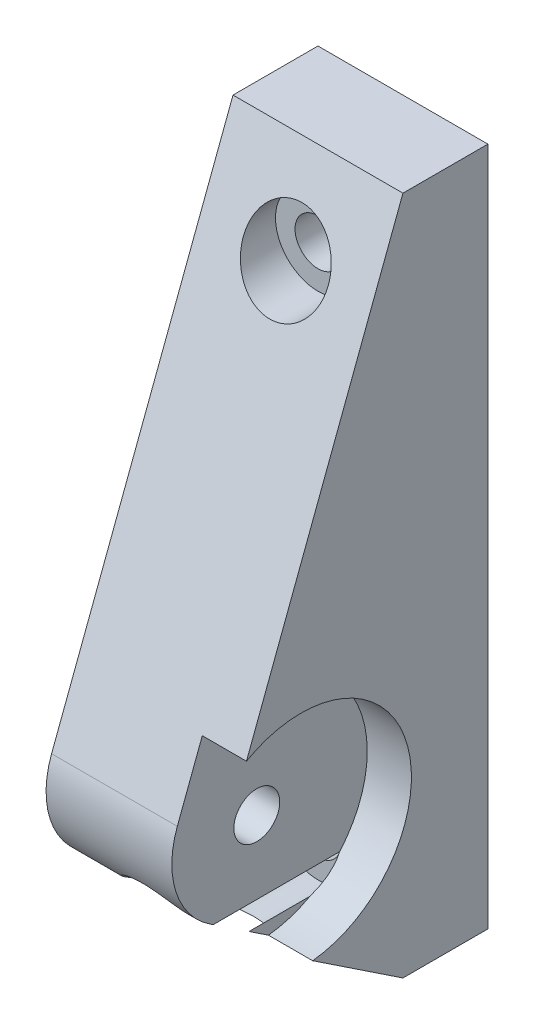
from build123d import *

# Parameters (mm, degrees)
SKETCH1_W           = 20
SKETCH1_H           = 80
SKETCH1_R           = 2.7
BOSS_EXTRUDE1_DEPTH = 10
SKETCH2_R           = 2.7
BOSS_EXTRUDE2_DEPTH = 10
SKETCH3_R           = 5
CUT_EXTRUDE1_DEPTH  = 75.054034326
SKETCH4_R           = 13
CUT_EXTRUDE2_DEPTH  = 5.2


with BuildPart() as part:
    # Sketch1 → Boss-Extrude1 (new body)
    with BuildSketch(Plane.XY):
        with Locations((0, -30)):
            Rectangle(SKETCH1_W, SKETCH1_H)
        Circle(SKETCH1_R, mode=Mode.SUBTRACT)
        with Locations((0, -60)):
            Circle(SKETCH1_R, mode=Mode.SUBTRACT)
    extrude(amount=BOSS_EXTRUDE1_DEPTH)

    # Sketch2 → Boss-Extrude2 (add, symmetric)
    with BuildSketch(Plane(origin=(0, 0, 0), x_dir=(0, 0, -1), z_dir=(1, 0, 0))):
        with BuildLine():
            Line((-10, 10), (-31.353454021, -46.462642529))
            ThreePointArc((-31.353454021, -46.462642529), (-31.520338182, -53.05992825), (-27.540921877, -58.324553126))
            Line((-27.540921877, -58.324553126), (-10, -70))
            Line((-10, -70), (-10, 10))
        make_face()
        with Locations((-22, -50)):
            Circle(SKETCH2_R, mode=Mode.SUBTRACT)
    extrude(amount=BOSS_EXTRUDE2_DEPTH, both=True)

    # Sketch3 → Cut-Extrude1 (cut, through all)
    with BuildSketch(Plane(origin=(0, 0, 10), x_dir=(-1, 0, 0), z_dir=(0, 0, -1))):
        with Locations((0, -60)):
            Circle(SKETCH3_R)
        Circle(SKETCH3_R)
    extrude(amount=-CUT_EXTRUDE1_DEPTH, mode=Mode.SUBTRACT)

    # Sketch4 → Cut-Extrude2 (cut)
    with BuildSketch(Plane(origin=(10, 0, 0), x_dir=(0, 0, -1), z_dir=(1, 0, 0))):
        with Locations((-22, -50)):
            Circle(SKETCH4_R)
    extrude(amount=-CUT_EXTRUDE2_DEPTH, mode=Mode.SUBTRACT)


solid = part.part
